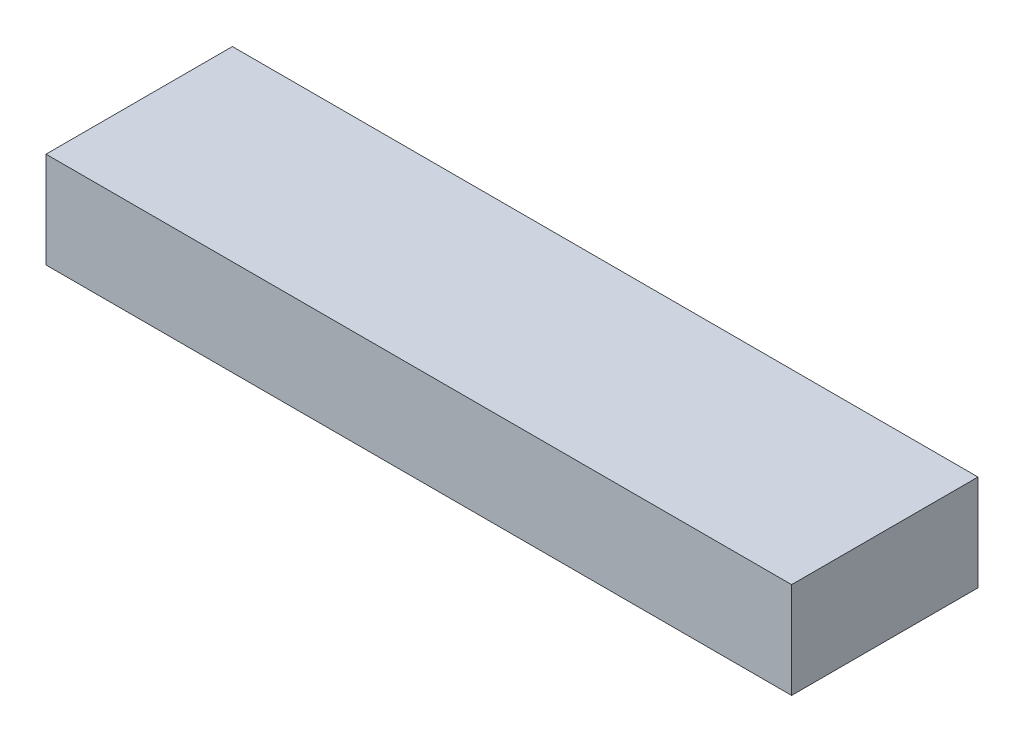
from build123d import *

# Parameters (mm, degrees)
SKETCH1_W                = 16000
SKETCH1_H                = 4000
BOSS_EXTRUDE1_DEPTH      = 2000
BOSS_EXTRUDE1_DEPTH_BACK = 60


with BuildPart() as part:
    # Sketch1 → Boss-Extrude1 (new body, two sides)
    with BuildSketch(Plane(origin=(0, 0, 0), x_dir=(1, 0, 0), z_dir=(0, 1, 0))) as boss_extrude1_sk:
        Rectangle(SKETCH1_W, SKETCH1_H)
    extrude(amount=BOSS_EXTRUDE1_DEPTH)
    extrude(boss_extrude1_sk.sketch, amount=-BOSS_EXTRUDE1_DEPTH_BACK)


solid = part.part
